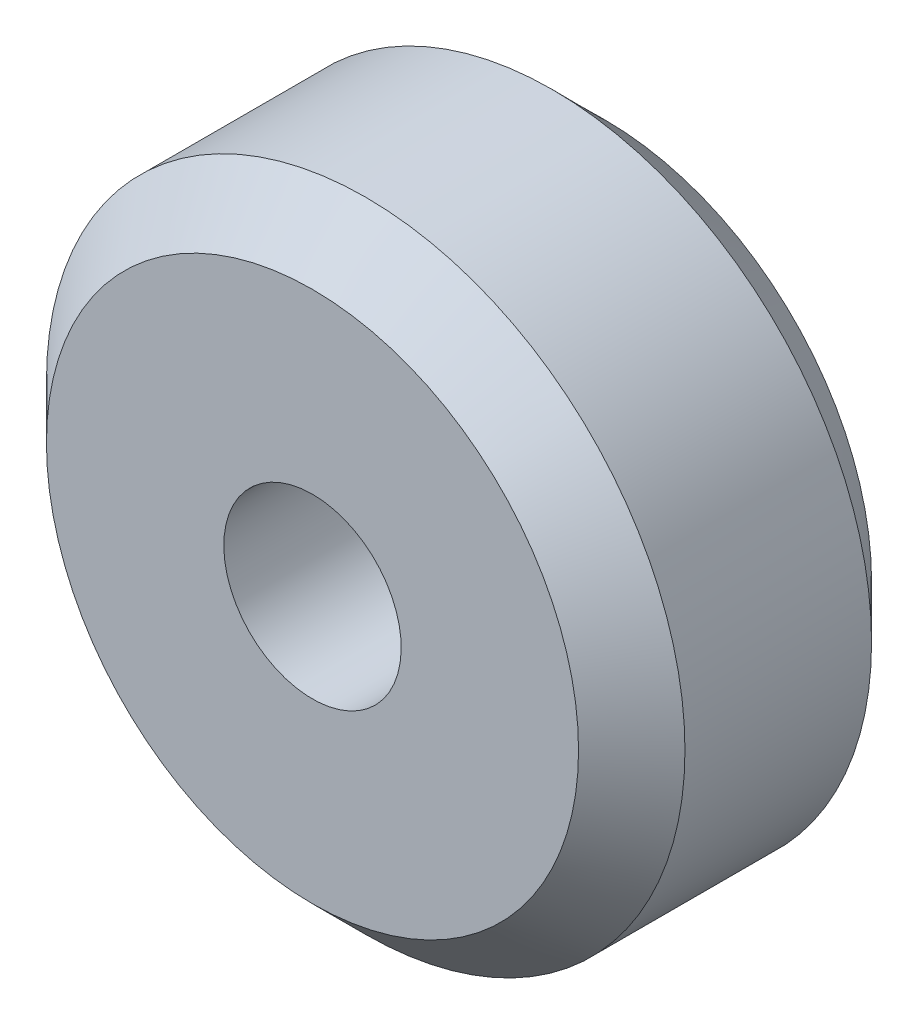
from build123d import *

# Parameters (mm, degrees)
SKETCH2_R          = 2.5
CUT_EXTRUDE1_DEPTH = 9.26


with BuildPart() as part:
    # Sketch1 → Revolve1 (revolve)
    with BuildSketch(Plane(origin=(0, 0, 0), x_dir=(0, 0, -1), z_dir=(1, 0, 0))):
        Polygon((0, 0), (5.26, 0), (6.76, 1.5), (6.76, 9), (-1.5, 9), (-1.5, 1.5), align=None)
    revolve(axis=Axis((0, 9, 1.5), (0, 0, -1)))

    # Sketch2 → Cut-Extrude1 (cut, through all)
    with BuildSketch(Plane(origin=(0, 0, -6.76), x_dir=(-1, 0, 0), z_dir=(0, 0, -1))):
        with Locations((0, 9)):
            Circle(SKETCH2_R)
    extrude(amount=-CUT_EXTRUDE1_DEPTH, mode=Mode.SUBTRACT)


solid = part.part
